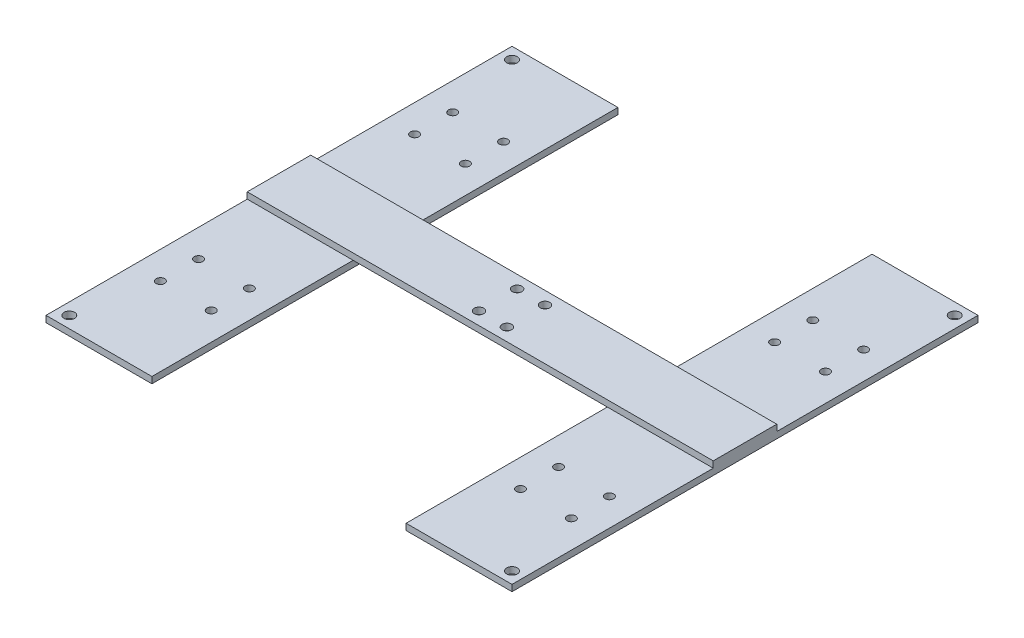
from build123d import *

# Parameters (mm, degrees)
SKETCH1_W           = 50
SKETCH1_H           = 220
SKETCH1_R           = 2
SKETCH1_R_2         = 2.5
SKETCH1_H_2         = 95
BOSS_EXTRUDE1_DEPTH = 3
BOSS_EXTRUDE2_START = 3
SKETCH1_4_W         = 220
SKETCH1_4_H         = 30
SKETCH1_4_R         = 2.25
BOSS_EXTRUDE2_DEPTH = 3


with BuildPart() as part:
    # Sketch1 → Boss-Extrude1 (new body)
    with BuildSketch(Plane(origin=(0, 0, 0), x_dir=(1, 0, 0), z_dir=(0, 1, 0))):
        with Locations((-85, 0)):
            Rectangle(SKETCH1_W, SKETCH1_H)
        with Locations(Location((-97, -69, 0), (0, 0, 270))):
            Circle(SKETCH1_R, mode=Mode.SUBTRACT)
        with Locations(Location((-73, -51, 0), (0, 0, 270))):
            Circle(SKETCH1_R, mode=Mode.SUBTRACT)
        with Locations(Location((-97, 69, 0), (0, 0, 270))):
            Circle(SKETCH1_R, mode=Mode.SUBTRACT)
        with Locations(Location((-73, 69, 0), (0, 0, 270))):
            Circle(SKETCH1_R, mode=Mode.SUBTRACT)
        with Locations(Location((-73, 51, 0), (0, 0, 270))):
            Circle(SKETCH1_R, mode=Mode.SUBTRACT)
        with Locations(Location((-97, 51, 0), (0, 0, 270))):
            Circle(SKETCH1_R, mode=Mode.SUBTRACT)
        with Locations(Location((-97, -51, 0), (0, 0, 270))):
            Circle(SKETCH1_R, mode=Mode.SUBTRACT)
        with Locations(Location((-73, -69, 0), (0, 0, 270))):
            Circle(SKETCH1_R, mode=Mode.SUBTRACT)
        with Locations(Location((-104.5, 104.5, 0), (0, 0, 270))):
            Circle(SKETCH1_R_2, mode=Mode.SUBTRACT)
        with Locations(Location((-104.5, -104.5, 0), (0, 0, 270))):
            Circle(SKETCH1_R_2, mode=Mode.SUBTRACT)
        with Locations((85, 0)):
            Rectangle(SKETCH1_W, SKETCH1_H)
        with Locations(Location((104.5, -104.5, 0), (0, 0, 270))):
            Circle(SKETCH1_R_2, mode=Mode.SUBTRACT)
        with Locations(Location((97, 69, 0), (0, 0, 270))):
            Circle(SKETCH1_R, mode=Mode.SUBTRACT)
        with Locations(Location((73, 51, 0), (0, 0, 270))):
            Circle(SKETCH1_R, mode=Mode.SUBTRACT)
        with Locations(Location((97, 51, 0), (0, 0, 270))):
            Circle(SKETCH1_R, mode=Mode.SUBTRACT)
        with Locations(Location((73, 69, 0), (0, 0, 270))):
            Circle(SKETCH1_R, mode=Mode.SUBTRACT)
        with Locations(Location((97, -69, 0), (0, 0, 270))):
            Circle(SKETCH1_R, mode=Mode.SUBTRACT)
        with Locations(Location((73, -69, 0), (0, 0, 270))):
            Circle(SKETCH1_R, mode=Mode.SUBTRACT)
        with Locations(Location((73, -51, 0), (0, 0, 270))):
            Circle(SKETCH1_R, mode=Mode.SUBTRACT)
        with Locations(Location((97, -51, 0), (0, 0, 270))):
            Circle(SKETCH1_R, mode=Mode.SUBTRACT)
        with Locations(Location((104.5, 104.5, 0), (0, 0, 270))):
            Circle(SKETCH1_R_2, mode=Mode.SUBTRACT)
        with Locations((-85, -62.5)):
            Rectangle(SKETCH1_W, SKETCH1_H_2)
        with Locations(Location((-104.5, -104.5, 0), (0, 0, 270))):
            Circle(SKETCH1_R_2, mode=Mode.SUBTRACT)
        with Locations(Location((-97, -69, 0), (0, 0, 270))):
            Circle(SKETCH1_R, mode=Mode.SUBTRACT)
        with Locations(Location((-73, -69, 0), (0, 0, 270))):
            Circle(SKETCH1_R, mode=Mode.SUBTRACT)
        with Locations(Location((-97, -51, 0), (0, 0, 270))):
            Circle(SKETCH1_R, mode=Mode.SUBTRACT)
        with Locations(Location((-73, -51, 0), (0, 0, 270))):
            Circle(SKETCH1_R, mode=Mode.SUBTRACT)
        with Locations((-85, 62.5)):
            Rectangle(SKETCH1_W, SKETCH1_H_2)
        with Locations(Location((-97, 51, 0), (0, 0, 270))):
            Circle(SKETCH1_R, mode=Mode.SUBTRACT)
        with Locations(Location((-73, 51, 0), (0, 0, 270))):
            Circle(SKETCH1_R, mode=Mode.SUBTRACT)
        with Locations(Location((-97, 69, 0), (0, 0, 270))):
            Circle(SKETCH1_R, mode=Mode.SUBTRACT)
        with Locations(Location((-73, 69, 0), (0, 0, 270))):
            Circle(SKETCH1_R, mode=Mode.SUBTRACT)
        with Locations(Location((-104.5, 104.5, 0), (0, 0, 270))):
            Circle(SKETCH1_R_2, mode=Mode.SUBTRACT)
        with Locations((85, 62.5)):
            Rectangle(SKETCH1_W, SKETCH1_H_2)
        with Locations(Location((73, 51, 0), (0, 0, 270))):
            Circle(SKETCH1_R, mode=Mode.SUBTRACT)
        with Locations(Location((97, 51, 0), (0, 0, 270))):
            Circle(SKETCH1_R, mode=Mode.SUBTRACT)
        with Locations(Location((73, 69, 0), (0, 0, 270))):
            Circle(SKETCH1_R, mode=Mode.SUBTRACT)
        with Locations(Location((97, 69, 0), (0, 0, 270))):
            Circle(SKETCH1_R, mode=Mode.SUBTRACT)
        with Locations(Location((104.5, 104.5, 0), (0, 0, 270))):
            Circle(SKETCH1_R_2, mode=Mode.SUBTRACT)
        with Locations((85, -62.5)):
            Rectangle(SKETCH1_W, SKETCH1_H_2)
        with Locations(Location((104.5, -104.5, 0), (0, 0, 270))):
            Circle(SKETCH1_R_2, mode=Mode.SUBTRACT)
        with Locations(Location((73, -69, 0), (0, 0, 270))):
            Circle(SKETCH1_R, mode=Mode.SUBTRACT)
        with Locations(Location((97, -69, 0), (0, 0, 270))):
            Circle(SKETCH1_R, mode=Mode.SUBTRACT)
        with Locations(Location((73, -51, 0), (0, 0, 270))):
            Circle(SKETCH1_R, mode=Mode.SUBTRACT)
        with Locations(Location((97, -51, 0), (0, 0, 270))):
            Circle(SKETCH1_R, mode=Mode.SUBTRACT)
    extrude(amount=BOSS_EXTRUDE1_DEPTH)

    # Sketch1_4 → Boss-Extrude2 (add)
    with BuildSketch(Plane(origin=(0, 0, 0), x_dir=(1, 0, 0), z_dir=(0, 1, 0)).offset(BOSS_EXTRUDE2_START)):
        Rectangle(SKETCH1_4_W, SKETCH1_4_H)
        with Locations(Location((6.575, 9, 0), (0, 0, 270))):
            Circle(SKETCH1_4_R, mode=Mode.SUBTRACT)
        with Locations(Location((-6.575, -9, 0), (0, 0, 270))):
            Circle(SKETCH1_4_R, mode=Mode.SUBTRACT)
        with Locations(Location((6.575, -9, 0), (0, 0, 270))):
            Circle(SKETCH1_4_R, mode=Mode.SUBTRACT)
        with Locations(Location((-6.575, 9, 0), (0, 0, 270))):
            Circle(SKETCH1_4_R, mode=Mode.SUBTRACT)
    extrude(amount=BOSS_EXTRUDE2_DEPTH)


solid = part.part
